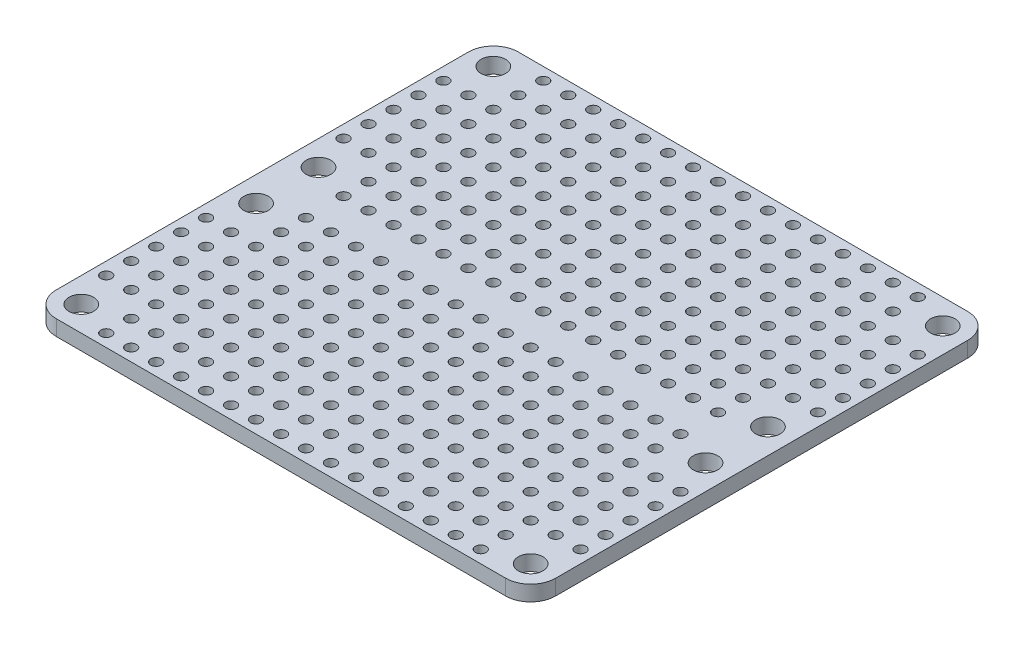
from build123d import *

# Parameters (mm, degrees)
SKETCH1_W               = 50.8
SKETCH1_H               = 47
SKETCH1_R               = 1.25
BOSS_EXTRUDE1_DEPTH     = 1.57
SKETCH4_R               = 0.55
CUT_EXTRUDE2_DEPTH      = 2.57
MIRROR2_COPY_1_SKETCH_R = 0.55
MIRROR2_COPY_1_DEPTH    = 2.57
FILLET1_R               = 2.54


with BuildPart() as part:
    # Sketch1 → Boss-Extrude1 (new body)
    with BuildSketch(Plane(origin=(0, 0, 0), x_dir=(1, 0, 0), z_dir=(0, 1, 0))):
        with Locations((25.4, 23.5)):
            Rectangle(SKETCH1_W, SKETCH1_H)
        with Locations((2.54, 44.46)):
            Circle(SKETCH1_R, mode=Mode.SUBTRACT)
        with Locations((2.54, 26.675)):
            Circle(SKETCH1_R, mode=Mode.SUBTRACT)
        with Locations((48.26, 26.675)):
            Circle(SKETCH1_R, mode=Mode.SUBTRACT)
        with Locations((48.26, 44.46)):
            Circle(SKETCH1_R, mode=Mode.SUBTRACT)
        with Locations((48.26, 20.325)):
            Circle(SKETCH1_R, mode=Mode.SUBTRACT)
        with Locations((48.26, 2.54)):
            Circle(SKETCH1_R, mode=Mode.SUBTRACT)
        with Locations((2.54, 2.54)):
            Circle(SKETCH1_R, mode=Mode.SUBTRACT)
        with Locations((2.54, 20.325)):
            Circle(SKETCH1_R, mode=Mode.SUBTRACT)
    extrude(amount=BOSS_EXTRUDE1_DEPTH)

    # Sketch4 → Cut-Extrude2 (cut, through all)
    with BuildSketch(Plane(origin=(0, 0, 0), x_dir=(1, 0, 0), z_dir=(0, 1, 0))):
        with Locations((6.35, 45.73)):
            Circle(SKETCH4_R)
        with Locations((8.89, 45.73)):
            Circle(SKETCH4_R)
        with Locations((11.43, 45.73)):
            Circle(SKETCH4_R)
        with Locations((13.97, 45.73)):
            Circle(SKETCH4_R)
        with Locations((16.51, 45.73)):
            Circle(SKETCH4_R)
        with Locations((19.05, 45.73)):
            Circle(SKETCH4_R)
        with Locations((21.59, 45.73)):
            Circle(SKETCH4_R)
        with Locations((24.13, 45.73)):
            Circle(SKETCH4_R)
        with Locations((6.35, 43.19)):
            Circle(SKETCH4_R)
        with Locations((8.89, 43.19)):
            Circle(SKETCH4_R)
        with Locations((11.43, 43.19)):
            Circle(SKETCH4_R)
        with Locations((13.97, 43.19)):
            Circle(SKETCH4_R)
        with Locations((16.51, 43.19)):
            Circle(SKETCH4_R)
        with Locations((19.05, 43.19)):
            Circle(SKETCH4_R)
        with Locations((21.59, 43.19)):
            Circle(SKETCH4_R)
        with Locations((24.13, 43.19)):
            Circle(SKETCH4_R)
        with Locations((6.35, 40.65)):
            Circle(SKETCH4_R)
        with Locations((8.89, 40.65)):
            Circle(SKETCH4_R)
        with Locations((11.43, 40.65)):
            Circle(SKETCH4_R)
        with Locations((13.97, 40.65)):
            Circle(SKETCH4_R)
        with Locations((16.51, 40.65)):
            Circle(SKETCH4_R)
        with Locations((19.05, 40.65)):
            Circle(SKETCH4_R)
        with Locations((21.59, 40.65)):
            Circle(SKETCH4_R)
        with Locations((24.13, 40.65)):
            Circle(SKETCH4_R)
        with Locations((6.35, 38.11)):
            Circle(SKETCH4_R)
        with Locations((8.89, 38.11)):
            Circle(SKETCH4_R)
        with Locations((11.43, 38.11)):
            Circle(SKETCH4_R)
        with Locations((13.97, 38.11)):
            Circle(SKETCH4_R)
        with Locations((16.51, 38.11)):
            Circle(SKETCH4_R)
        with Locations((19.05, 38.11)):
            Circle(SKETCH4_R)
        with Locations((21.59, 38.11)):
            Circle(SKETCH4_R)
        with Locations((24.13, 38.11)):
            Circle(SKETCH4_R)
        with Locations((6.35, 35.57)):
            Circle(SKETCH4_R)
        with Locations((8.89, 35.57)):
            Circle(SKETCH4_R)
        with Locations((11.43, 35.57)):
            Circle(SKETCH4_R)
        with Locations((13.97, 35.57)):
            Circle(SKETCH4_R)
        with Locations((16.51, 35.57)):
            Circle(SKETCH4_R)
        with Locations((19.05, 35.57)):
            Circle(SKETCH4_R)
        with Locations((21.59, 35.57)):
            Circle(SKETCH4_R)
        with Locations((24.13, 35.57)):
            Circle(SKETCH4_R)
        with Locations((6.35, 33.03)):
            Circle(SKETCH4_R)
        with Locations((8.89, 33.03)):
            Circle(SKETCH4_R)
        with Locations((11.43, 33.03)):
            Circle(SKETCH4_R)
        with Locations((13.97, 33.03)):
            Circle(SKETCH4_R)
        with Locations((16.51, 33.03)):
            Circle(SKETCH4_R)
        with Locations((19.05, 33.03)):
            Circle(SKETCH4_R)
        with Locations((21.59, 33.03)):
            Circle(SKETCH4_R)
        with Locations((24.13, 33.03)):
            Circle(SKETCH4_R)
        with Locations((6.35, 30.49)):
            Circle(SKETCH4_R)
        with Locations((8.89, 30.49)):
            Circle(SKETCH4_R)
        with Locations((11.43, 30.49)):
            Circle(SKETCH4_R)
        with Locations((13.97, 30.49)):
            Circle(SKETCH4_R)
        with Locations((16.51, 30.49)):
            Circle(SKETCH4_R)
        with Locations((19.05, 30.49)):
            Circle(SKETCH4_R)
        with Locations((21.59, 30.49)):
            Circle(SKETCH4_R)
        with Locations((24.13, 30.49)):
            Circle(SKETCH4_R)
        with Locations((6.35, 27.95)):
            Circle(SKETCH4_R)
        with Locations((8.89, 27.95)):
            Circle(SKETCH4_R)
        with Locations((11.43, 27.95)):
            Circle(SKETCH4_R)
        with Locations((13.97, 27.95)):
            Circle(SKETCH4_R)
        with Locations((16.51, 27.95)):
            Circle(SKETCH4_R)
        with Locations((19.05, 27.95)):
            Circle(SKETCH4_R)
        with Locations((21.59, 27.95)):
            Circle(SKETCH4_R)
        with Locations((24.13, 27.95)):
            Circle(SKETCH4_R)
        with Locations((6.35, 25.41)):
            Circle(SKETCH4_R)
        with Locations((8.89, 25.41)):
            Circle(SKETCH4_R)
        with Locations((11.43, 25.41)):
            Circle(SKETCH4_R)
        with Locations((13.97, 25.41)):
            Circle(SKETCH4_R)
        with Locations((16.51, 25.41)):
            Circle(SKETCH4_R)
        with Locations((19.05, 25.41)):
            Circle(SKETCH4_R)
        with Locations((21.59, 25.41)):
            Circle(SKETCH4_R)
        with Locations((24.13, 25.41)):
            Circle(SKETCH4_R)
        with Locations((3.81, 40.65)):
            Circle(SKETCH4_R)
        with Locations((3.81, 38.11)):
            Circle(SKETCH4_R)
        with Locations((3.81, 35.57)):
            Circle(SKETCH4_R)
        with Locations((3.81, 33.03)):
            Circle(SKETCH4_R)
        with Locations((3.81, 30.49)):
            Circle(SKETCH4_R)
        with Locations((1.27, 40.65)):
            Circle(SKETCH4_R)
        with Locations((1.27, 38.11)):
            Circle(SKETCH4_R)
        with Locations((1.27, 35.57)):
            Circle(SKETCH4_R)
        with Locations((1.27, 33.03)):
            Circle(SKETCH4_R)
        with Locations((1.27, 30.49)):
            Circle(SKETCH4_R)
    cut_extrude2 = extrude(amount=CUT_EXTRUDE2_DEPTH, mode=Mode.SUBTRACT)

    # Mirror1: Cut-Extrude2 across plane
    add(cut_extrude2.mirror(Plane.ZY.offset(-25.4)), mode=Mode.SUBTRACT)

    # Mirror2: Cut-Extrude2 across plane
    add(cut_extrude2.mirror(Plane.XY.offset(-23.5)), mode=Mode.SUBTRACT)

    # Mirror2 copy 1 sketch → Mirror2 copy 1 (cut, through all)
    with BuildSketch(Plane(origin=(50.8, 0, -47), x_dir=(-1, 0, 0), z_dir=(0, 1, 0))):
        with Locations((6.35, 45.73)):
            Circle(MIRROR2_COPY_1_SKETCH_R)
        with Locations((8.89, 45.73)):
            Circle(MIRROR2_COPY_1_SKETCH_R)
        with Locations((11.43, 45.73)):
            Circle(MIRROR2_COPY_1_SKETCH_R)
        with Locations((13.97, 45.73)):
            Circle(MIRROR2_COPY_1_SKETCH_R)
        with Locations((16.51, 45.73)):
            Circle(MIRROR2_COPY_1_SKETCH_R)
        with Locations((19.05, 45.73)):
            Circle(MIRROR2_COPY_1_SKETCH_R)
        with Locations((21.59, 45.73)):
            Circle(MIRROR2_COPY_1_SKETCH_R)
        with Locations((24.13, 45.73)):
            Circle(MIRROR2_COPY_1_SKETCH_R)
        with Locations((6.35, 43.19)):
            Circle(MIRROR2_COPY_1_SKETCH_R)
        with Locations((8.89, 43.19)):
            Circle(MIRROR2_COPY_1_SKETCH_R)
        with Locations((11.43, 43.19)):
            Circle(MIRROR2_COPY_1_SKETCH_R)
        with Locations((13.97, 43.19)):
            Circle(MIRROR2_COPY_1_SKETCH_R)
        with Locations((16.51, 43.19)):
            Circle(MIRROR2_COPY_1_SKETCH_R)
        with Locations((19.05, 43.19)):
            Circle(MIRROR2_COPY_1_SKETCH_R)
        with Locations((21.59, 43.19)):
            Circle(MIRROR2_COPY_1_SKETCH_R)
        with Locations((24.13, 43.19)):
            Circle(MIRROR2_COPY_1_SKETCH_R)
        with Locations((6.35, 40.65)):
            Circle(MIRROR2_COPY_1_SKETCH_R)
        with Locations((8.89, 40.65)):
            Circle(MIRROR2_COPY_1_SKETCH_R)
        with Locations((11.43, 40.65)):
            Circle(MIRROR2_COPY_1_SKETCH_R)
        with Locations((13.97, 40.65)):
            Circle(MIRROR2_COPY_1_SKETCH_R)
        with Locations((16.51, 40.65)):
            Circle(MIRROR2_COPY_1_SKETCH_R)
        with Locations((19.05, 40.65)):
            Circle(MIRROR2_COPY_1_SKETCH_R)
        with Locations((21.59, 40.65)):
            Circle(MIRROR2_COPY_1_SKETCH_R)
        with Locations((24.13, 40.65)):
            Circle(MIRROR2_COPY_1_SKETCH_R)
        with Locations((6.35, 38.11)):
            Circle(MIRROR2_COPY_1_SKETCH_R)
        with Locations((8.89, 38.11)):
            Circle(MIRROR2_COPY_1_SKETCH_R)
        with Locations((11.43, 38.11)):
            Circle(MIRROR2_COPY_1_SKETCH_R)
        with Locations((13.97, 38.11)):
            Circle(MIRROR2_COPY_1_SKETCH_R)
        with Locations((16.51, 38.11)):
            Circle(MIRROR2_COPY_1_SKETCH_R)
        with Locations((19.05, 38.11)):
            Circle(MIRROR2_COPY_1_SKETCH_R)
        with Locations((21.59, 38.11)):
            Circle(MIRROR2_COPY_1_SKETCH_R)
        with Locations((24.13, 38.11)):
            Circle(MIRROR2_COPY_1_SKETCH_R)
        with Locations((6.35, 35.57)):
            Circle(MIRROR2_COPY_1_SKETCH_R)
        with Locations((8.89, 35.57)):
            Circle(MIRROR2_COPY_1_SKETCH_R)
        with Locations((11.43, 35.57)):
            Circle(MIRROR2_COPY_1_SKETCH_R)
        with Locations((13.97, 35.57)):
            Circle(MIRROR2_COPY_1_SKETCH_R)
        with Locations((16.51, 35.57)):
            Circle(MIRROR2_COPY_1_SKETCH_R)
        with Locations((19.05, 35.57)):
            Circle(MIRROR2_COPY_1_SKETCH_R)
        with Locations((21.59, 35.57)):
            Circle(MIRROR2_COPY_1_SKETCH_R)
        with Locations((24.13, 35.57)):
            Circle(MIRROR2_COPY_1_SKETCH_R)
        with Locations((6.35, 33.03)):
            Circle(MIRROR2_COPY_1_SKETCH_R)
        with Locations((8.89, 33.03)):
            Circle(MIRROR2_COPY_1_SKETCH_R)
        with Locations((11.43, 33.03)):
            Circle(MIRROR2_COPY_1_SKETCH_R)
        with Locations((13.97, 33.03)):
            Circle(MIRROR2_COPY_1_SKETCH_R)
        with Locations((16.51, 33.03)):
            Circle(MIRROR2_COPY_1_SKETCH_R)
        with Locations((19.05, 33.03)):
            Circle(MIRROR2_COPY_1_SKETCH_R)
        with Locations((21.59, 33.03)):
            Circle(MIRROR2_COPY_1_SKETCH_R)
        with Locations((24.13, 33.03)):
            Circle(MIRROR2_COPY_1_SKETCH_R)
        with Locations((6.35, 30.49)):
            Circle(MIRROR2_COPY_1_SKETCH_R)
        with Locations((8.89, 30.49)):
            Circle(MIRROR2_COPY_1_SKETCH_R)
        with Locations((11.43, 30.49)):
            Circle(MIRROR2_COPY_1_SKETCH_R)
        with Locations((13.97, 30.49)):
            Circle(MIRROR2_COPY_1_SKETCH_R)
        with Locations((16.51, 30.49)):
            Circle(MIRROR2_COPY_1_SKETCH_R)
        with Locations((19.05, 30.49)):
            Circle(MIRROR2_COPY_1_SKETCH_R)
        with Locations((21.59, 30.49)):
            Circle(MIRROR2_COPY_1_SKETCH_R)
        with Locations((24.13, 30.49)):
            Circle(MIRROR2_COPY_1_SKETCH_R)
        with Locations((6.35, 27.95)):
            Circle(MIRROR2_COPY_1_SKETCH_R)
        with Locations((8.89, 27.95)):
            Circle(MIRROR2_COPY_1_SKETCH_R)
        with Locations((11.43, 27.95)):
            Circle(MIRROR2_COPY_1_SKETCH_R)
        with Locations((13.97, 27.95)):
            Circle(MIRROR2_COPY_1_SKETCH_R)
        with Locations((16.51, 27.95)):
            Circle(MIRROR2_COPY_1_SKETCH_R)
        with Locations((19.05, 27.95)):
            Circle(MIRROR2_COPY_1_SKETCH_R)
        with Locations((21.59, 27.95)):
            Circle(MIRROR2_COPY_1_SKETCH_R)
        with Locations((24.13, 27.95)):
            Circle(MIRROR2_COPY_1_SKETCH_R)
        with Locations((6.35, 25.41)):
            Circle(MIRROR2_COPY_1_SKETCH_R)
        with Locations((8.89, 25.41)):
            Circle(MIRROR2_COPY_1_SKETCH_R)
        with Locations((11.43, 25.41)):
            Circle(MIRROR2_COPY_1_SKETCH_R)
        with Locations((13.97, 25.41)):
            Circle(MIRROR2_COPY_1_SKETCH_R)
        with Locations((16.51, 25.41)):
            Circle(MIRROR2_COPY_1_SKETCH_R)
        with Locations((19.05, 25.41)):
            Circle(MIRROR2_COPY_1_SKETCH_R)
        with Locations((21.59, 25.41)):
            Circle(MIRROR2_COPY_1_SKETCH_R)
        with Locations((24.13, 25.41)):
            Circle(MIRROR2_COPY_1_SKETCH_R)
        with Locations((3.81, 40.65)):
            Circle(MIRROR2_COPY_1_SKETCH_R)
        with Locations((3.81, 38.11)):
            Circle(MIRROR2_COPY_1_SKETCH_R)
        with Locations((3.81, 35.57)):
            Circle(MIRROR2_COPY_1_SKETCH_R)
        with Locations((3.81, 33.03)):
            Circle(MIRROR2_COPY_1_SKETCH_R)
        with Locations((3.81, 30.49)):
            Circle(MIRROR2_COPY_1_SKETCH_R)
        with Locations((1.27, 40.65)):
            Circle(MIRROR2_COPY_1_SKETCH_R)
        with Locations((1.27, 38.11)):
            Circle(MIRROR2_COPY_1_SKETCH_R)
        with Locations((1.27, 35.57)):
            Circle(MIRROR2_COPY_1_SKETCH_R)
        with Locations((1.27, 33.03)):
            Circle(MIRROR2_COPY_1_SKETCH_R)
        with Locations((1.27, 30.49)):
            Circle(MIRROR2_COPY_1_SKETCH_R)
    extrude(amount=MIRROR2_COPY_1_DEPTH, mode=Mode.SUBTRACT)

    # Fillet1
    fillet1_edges = [part.edges().sort_by_distance(p)[0] for p in [
        (0, 0.785, -47),
        (50.8, 0.785, -47),
        (50.8, 0.785, 0),
        (0, 0.785, 0),
    ]]
    fillet(fillet1_edges, radius=FILLET1_R)


solid = part.part
